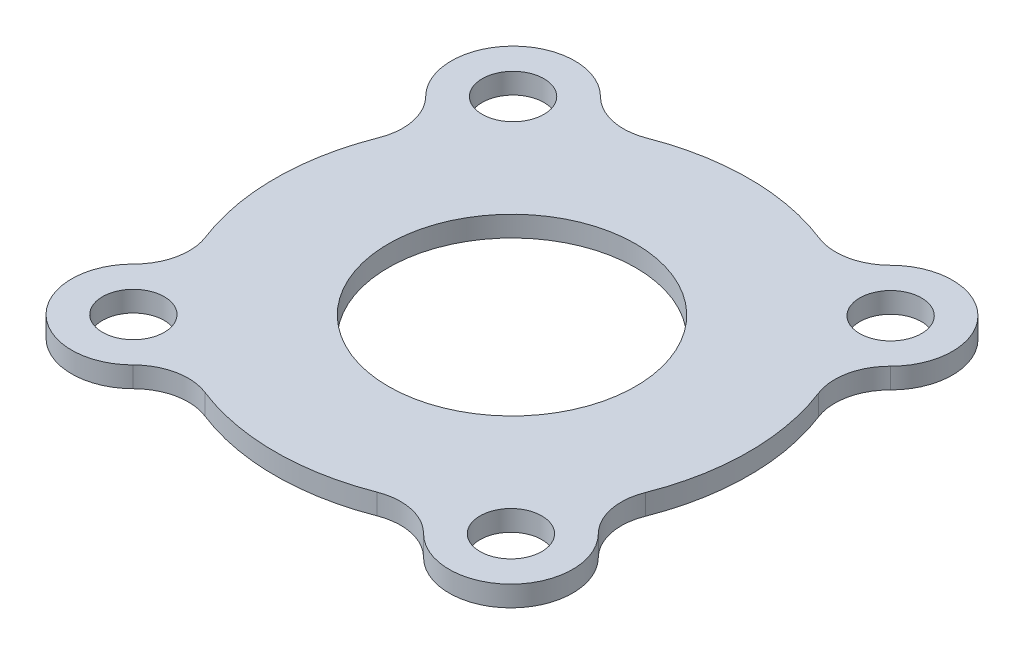
from build123d import *

# Parameters (mm, degrees)
SKETCH1_R           = 6
SKETCH1_R_2         = 1.5
BOSS_EXTRUDE1_DEPTH = 1
SKETCH3_R           = 9.5
SKETCH3_R_2         = 8
BOSS_EXTRUDE2_DEPTH = 1


with BuildPart() as part:
    # Sketch1 → Boss-Extrude1 (new body)
    with BuildSketch(Plane(origin=(0, 0, 0), x_dir=(1, 0, 0), z_dir=(0, 1, 0))):
        with BuildLine():
            ThreePointArc((10.722201854, 4.157449627), (10.598848399, 5.689199117), (11.333854237, 7.038731997))
            ThreePointArc((11.333854237, 7.038731997), (11.345969357, 11.281355386), (7.103345968, 11.293470506))
            ThreePointArc((7.103345968, 11.293470506), (5.749637406, 10.566183969), (4.218617379, 10.698283386))
            ThreePointArc((4.218617379, 10.698283386), (0.032838952, 11.499953113), (-4.157449627, 10.722201854))
            ThreePointArc((-4.157449627, 10.722201854), (-5.689199117, 10.598848399), (-7.038731997, 11.333854237))
            ThreePointArc((-7.038731997, 11.333854237), (-11.281355386, 11.345969357), (-11.293470506, 7.103345968))
            ThreePointArc((-11.293470506, 7.103345968), (-10.566183969, 5.749637406), (-10.698283386, 4.218617379))
            ThreePointArc((-10.698283386, 4.218617379), (-11.499953113, 0.032838952), (-10.722201854, -4.157449627))
            ThreePointArc((-10.722201854, -4.157449627), (-10.598848399, -5.689199117), (-11.333854237, -7.038731997))
            ThreePointArc((-11.333854237, -7.038731997), (-11.345969357, -11.281355386), (-7.103345968, -11.293470506))
            ThreePointArc((-7.103345968, -11.293470506), (-5.749637406, -10.566183969), (-4.218617379, -10.698283386))
            ThreePointArc((-4.218617379, -10.698283386), (-0.032838952, -11.499953113), (4.157449627, -10.722201854))
            ThreePointArc((4.157449627, -10.722201854), (5.689199117, -10.598848399), (7.038731997, -11.333854237))
            ThreePointArc((7.038731997, -11.333854237), (11.281355386, -11.345969357), (11.293470506, -7.103345968))
            ThreePointArc((11.293470506, -7.103345968), (10.566183969, -5.749637406), (10.698283386, -4.218617379))
            ThreePointArc((10.698283386, -4.218617379), (11.499953113, -0.032838952), (10.722201854, 4.157449627))
        make_face()
        Circle(SKETCH1_R, mode=Mode.SUBTRACT)
        with Locations((9.218600102, 9.166101251)):
            Circle(SKETCH1_R_2, mode=Mode.SUBTRACT)
        with Locations((9.166101251, -9.218600102)):
            Circle(SKETCH1_R_2, mode=Mode.SUBTRACT)
        with Locations((-9.166101251, 9.218600102)):
            Circle(SKETCH1_R_2, mode=Mode.SUBTRACT)
        with Locations((-9.218600102, -9.166101251)):
            Circle(SKETCH1_R_2, mode=Mode.SUBTRACT)
    extrude(amount=BOSS_EXTRUDE1_DEPTH)

    # Sketch3 → Boss-Extrude2 (add)
    with BuildSketch(Plane(origin=(0, 0, 0), x_dir=(1, 0, 0), z_dir=(0, 1, 0))):
        Circle(SKETCH3_R)
        Circle(SKETCH3_R_2, mode=Mode.SUBTRACT)
    extrude(amount=-BOSS_EXTRUDE2_DEPTH)


solid = part.part
